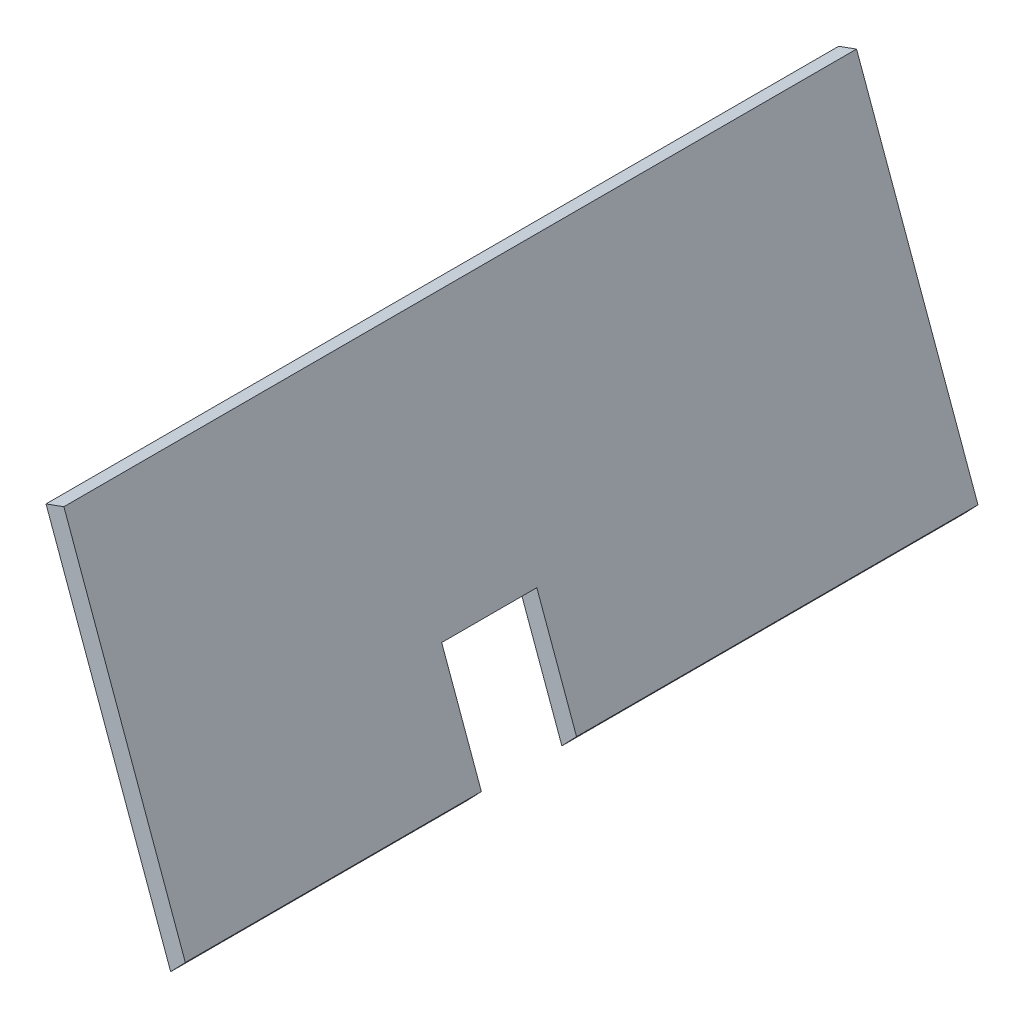
from build123d import *

# Parameters (mm, degrees)
BOSS_EXTRUDE1_DEPTH = 208.295833
SKETCH3_W           = 25
SKETCH3_H           = 33
CUT_EXTRUDE1_DEPTH  = 36.788128275


with BuildPart() as part:
    # Sketch2 → Boss-Extrude1 (new body)
    with BuildSketch(Plane.XY.offset(2)):
        Polygon((3386.129332678, -6568.675675181), (3418.890080551, -6658.762542636), (3422.744518293, -6654.731505307), (3390.828268184, -6566.966872936), align=None)
    extrude(amount=BOSS_EXTRUDE1_DEPTH)

    # Sketch3 → Cut-Extrude1 (cut, through all)
    with BuildSketch(Plane(origin=(885.586873602, 322.050140106, 0), x_dir=(0, 0, -1), z_dir=(0.939787101, 0.341760449, 0))):
        with Locations((-120, -7409.760556288)):
            Rectangle(SKETCH3_W, SKETCH3_H)
    extrude(amount=-CUT_EXTRUDE1_DEPTH, mode=Mode.SUBTRACT)


solid = part.part
